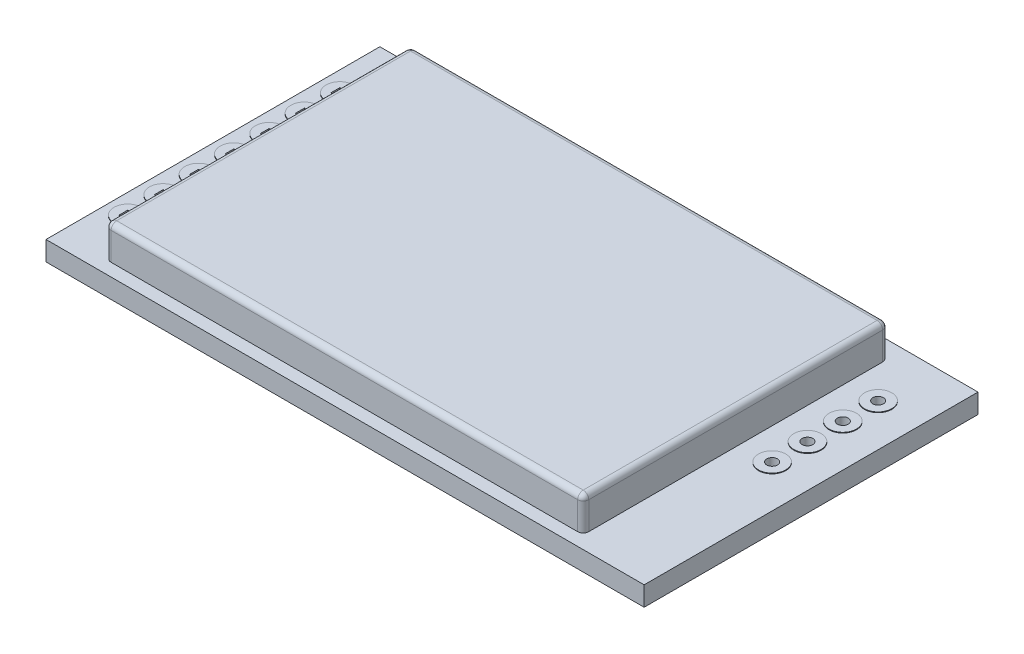
from build123d import *

# Parameters (mm, degrees)
CROQUIS1_W              = 43
CROQUIS1_H              = 24
SALIENTE_EXTRUIR1_DEPTH = 1.4
CROQUIS2_R              = 0.983927781
CROQUIS2_R_2            = 0.985
SALIENTE_EXTRUIR2_DEPTH = 0.05
CROQUIS3_W              = 0.64
CROQUIS3_H              = 0.64
CORTAR_EXTRUIR1_DEPTH   = 1.81
CROQUIS4_R              = 0.385
CORTAR_EXTRUIR2_DEPTH   = 1.81
CROQUIS5_W              = 34.338370929
CROQUIS5_H              = 21.924969232
SALIENTE_EXTRUIR3_DEPTH = 2.39
REDONDEO1_R             = 0.4


with BuildPart() as part:
    # Croquis1 → Saliente-Extruir1 (new body)
    with BuildSketch(Plane(origin=(0, 0, 0), x_dir=(1, 0, 0), z_dir=(0, 1, 0))):
        Rectangle(CROQUIS1_W, CROQUIS1_H)
    extrude(amount=SALIENTE_EXTRUIR1_DEPTH)

    # Croquis2 → Saliente-Extruir2 (add)
    with BuildSketch(Plane(origin=(0, 1.4, 0), x_dir=(1, 0, 0), z_dir=(0, 1, 0))):
        with Locations((-20.02, 7.64)):
            Circle(CROQUIS2_R)
        with Locations((-20.02, 5.1)):
            Circle(CROQUIS2_R)
        with Locations((-20.02, 2.56)):
            Circle(CROQUIS2_R)
        with Locations((-20.02, 0.02)):
            Circle(CROQUIS2_R)
        with Locations((-20.02, -2.52)):
            Circle(CROQUIS2_R)
        with Locations((-20.02, -5.06)):
            Circle(CROQUIS2_R)
        with Locations((-20.02, -7.6)):
            Circle(CROQUIS2_R)
        with Locations((18.5, 7.82)):
            Circle(CROQUIS2_R_2)
        with Locations((18.5, 5.28)):
            Circle(CROQUIS2_R_2)
        with Locations((18.5, 2.74)):
            Circle(CROQUIS2_R_2)
        with Locations((18.5, 0.2)):
            Circle(CROQUIS2_R_2)
    extrude(amount=SALIENTE_EXTRUIR2_DEPTH)

    # Croquis3 → Cortar-Extruir1 (cut)
    with BuildSketch(Plane(origin=(0, 1.45, 0), x_dir=(1, 0, 0), z_dir=(0, 1, 0))):
        with Locations((-20.02, 5.1)):
            Rectangle(CROQUIS3_W, CROQUIS3_H)
        with Locations((-20.02, 7.64)):
            Rectangle(CROQUIS3_W, CROQUIS3_H)
        with Locations((-20.02, 2.56)):
            Rectangle(CROQUIS3_W, CROQUIS3_H)
        with Locations((-20.02, 0.02)):
            Rectangle(CROQUIS3_W, CROQUIS3_H)
        with Locations((-20.02, -2.52)):
            Rectangle(CROQUIS3_W, CROQUIS3_H)
        with Locations((-20.02, -5.06)):
            Rectangle(CROQUIS3_W, CROQUIS3_H)
        with Locations((-20.02, -7.6)):
            Rectangle(CROQUIS3_W, CROQUIS3_H)
    extrude(amount=-CORTAR_EXTRUIR1_DEPTH, mode=Mode.SUBTRACT)

    # Croquis4 → Cortar-Extruir2 (cut)
    with BuildSketch(Plane(origin=(0, 1.45, 0), x_dir=(1, 0, 0), z_dir=(0, 1, 0))):
        with Locations((18.5, 5.28)):
            Circle(CROQUIS4_R)
        with Locations((18.5, 7.82)):
            Circle(CROQUIS4_R)
        with Locations((18.5, 2.74)):
            Circle(CROQUIS4_R)
        with Locations((18.5, 0.2)):
            Circle(CROQUIS4_R)
    extrude(amount=-CORTAR_EXTRUIR2_DEPTH, mode=Mode.SUBTRACT)

    # Croquis5 → Saliente-Extruir3 (add)
    with BuildSketch(Plane(origin=(0, 1.4, 0), x_dir=(1, 0, 0), z_dir=(0, 1, 0))):
        with Locations((-0.967278054, -0.120909757)):
            Rectangle(CROQUIS5_W, CROQUIS5_H)
    extrude(amount=SALIENTE_EXTRUIR3_DEPTH)

    # Redondeo1
    redondeo1_edges = [part.edges().sort_by_distance(p)[0] for p in [
        (-18.136463519, 2.595, -10.841574859),
        (-18.136463519, 2.595, 11.083394373),
        (16.20190741, 2.595, 11.083394373),
        (16.20190741, 2.595, -10.841574859),
        (-18.136463519, 3.79, 0.120909757),
        (-0.967278054, 3.79, 11.083394373),
        (16.20190741, 3.79, 0.120909757),
        (-0.967278054, 3.79, -10.841574859),
    ]]
    fillet(redondeo1_edges, radius=REDONDEO1_R)


solid = part.part
